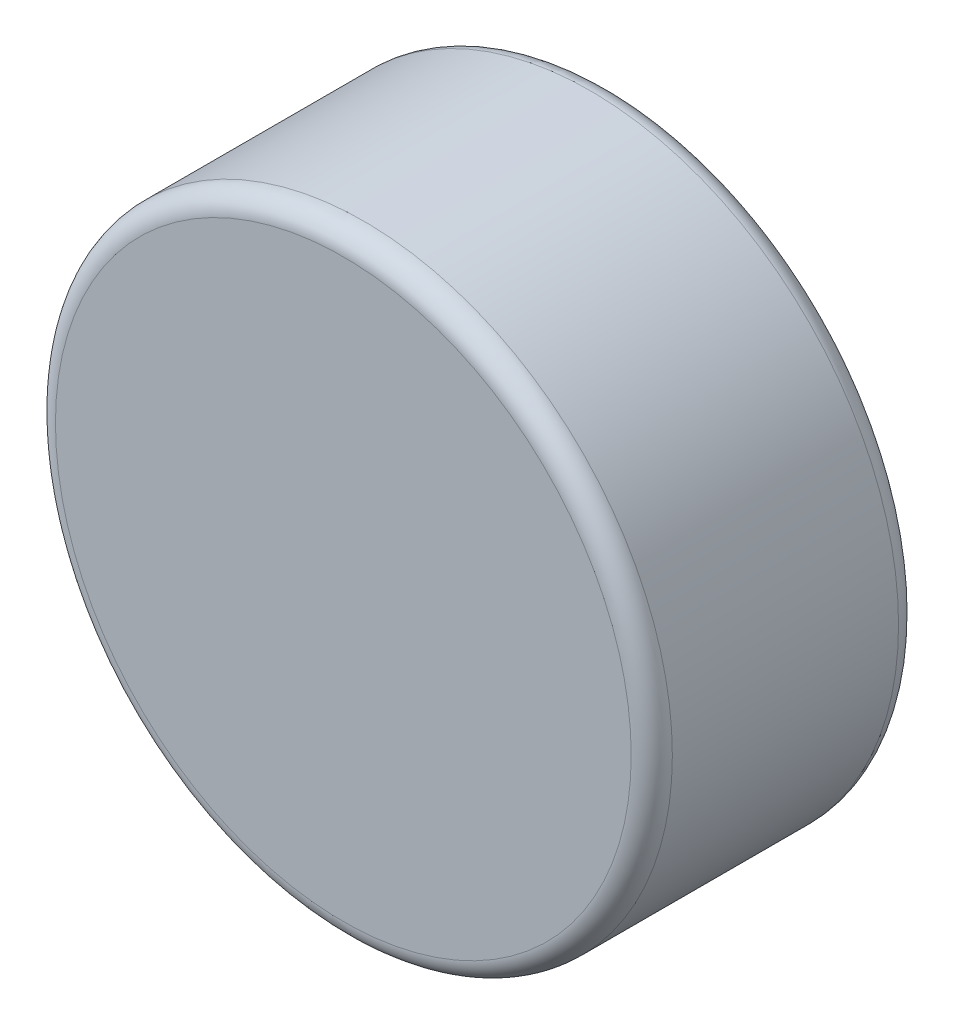
from build123d import *

# Parameters (mm, degrees)
ESQUISSE1_R        = 3
BOSS_EXTRU_1_DEPTH = 2.6
CONG_1_R           = 0.2


with BuildPart() as part:
    # Esquisse1 → Boss.-Extru.1 (new body)
    with BuildSketch(Plane.XY):
        Circle(ESQUISSE1_R)
    extrude(amount=BOSS_EXTRU_1_DEPTH)

    # Congé1
    cong_1_edges = [part.edges().sort_by_distance(p)[0] for p in [
        (-3, 0, 0),
        (-3, 0, 2.6),
    ]]
    fillet(cong_1_edges, radius=CONG_1_R)


solid = part.part
